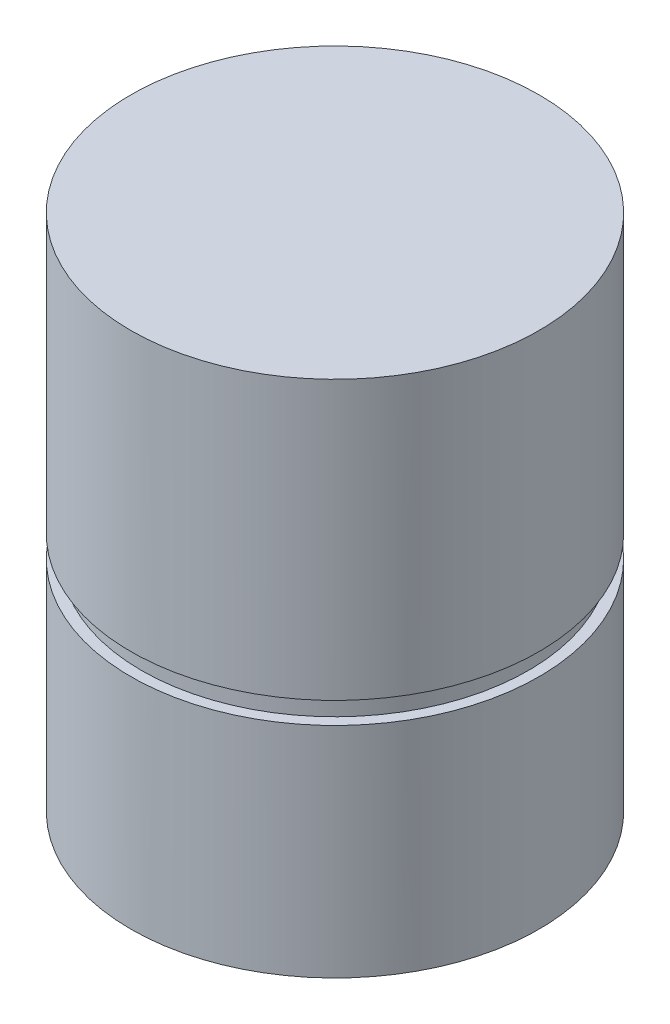
from build123d import *

# Parameters (mm, degrees)
SKETCH1_R           = 11
BOSS_EXTRUDE1_DEPTH = 27.94
SKETCH2_R           = 10.4267
CUT_EXTRUDE1_DEPTH  = 1.1684


with BuildPart() as part:
    # Sketch1 → Boss-Extrude1 (new body)
    with BuildSketch(Plane(origin=(0, 0, 0), x_dir=(1, 0, 0), z_dir=(0, 1, 0))):
        Circle(SKETCH1_R)
    extrude(amount=BOSS_EXTRUDE1_DEPTH)

    # Sketch2 → Cut-Extrude1 (cut)
    with BuildSketch(Plane(origin=(0, 12.954, 0), x_dir=(1, 0, 0), z_dir=(0, 1, 0))):
        with BuildLine():
            Line((-17.239436612, 14.563425366), (-16.28375247, -14.840830381))
            Line((-16.28375247, -14.840830381), (21.406068048, -16.295664576))
            Line((21.406068048, -16.295664576), (22.094276354, 14.197317514))
            Line((22.094276354, 14.197317514), (19.887741586, 14.563425366))
            ThreePointArc((19.887741586, 14.563425366), (1.324152487, 14.86501853), (-17.239436612, 14.563425366))
        make_face()
        Circle(SKETCH2_R, mode=Mode.SUBTRACT)
    extrude(amount=-CUT_EXTRUDE1_DEPTH, mode=Mode.SUBTRACT)


solid = part.part
